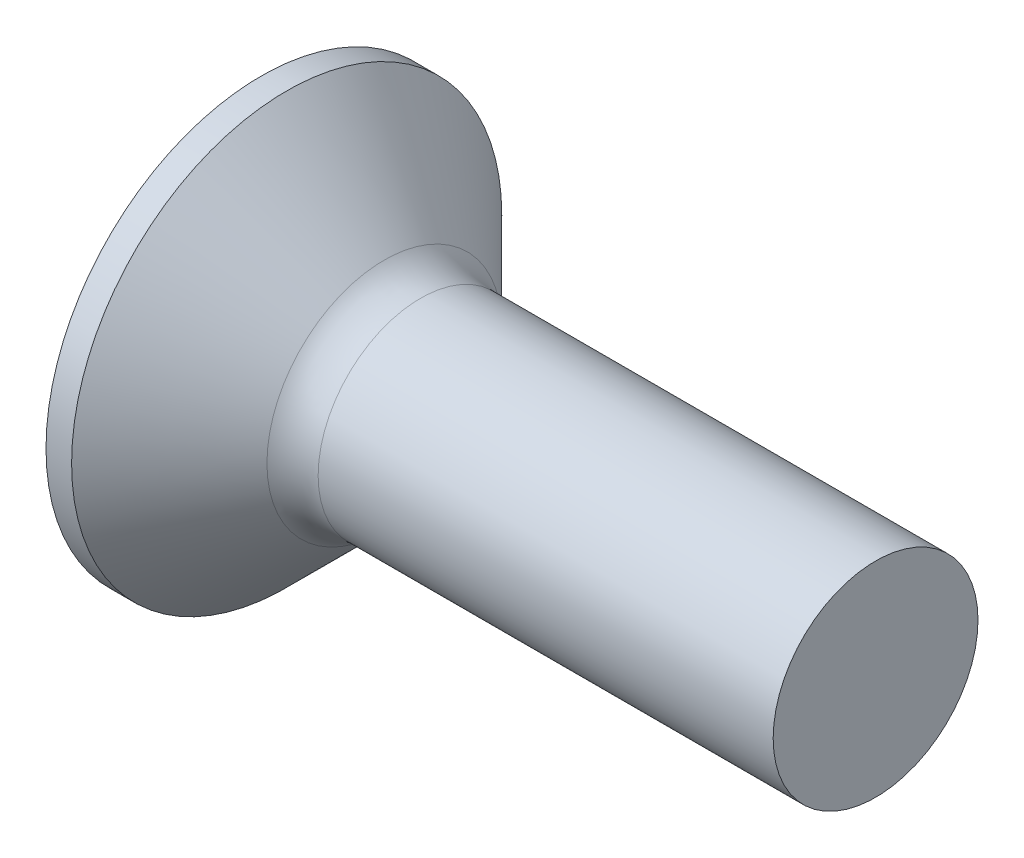
from build123d import *

# Parameters (mm, degrees)
FILLET1_R    = 1
SKETCH3_W    = 1.03
SKETCH3_H    = 4.4
SKETCH4_W    = 1.03
SKETCH4_H    = 1.897120414
RECPAT_COUNT = 2
RECPAT_ANGLE = 90


with BuildPart() as part:
    # BodySke → Base-Revolve (revolve)
    with BuildSketch(Plane.XY):
        Polygon((0, 0), (0, 4.2), (0.5, 4.2), (2.7, 2), (12, 2), (12, 0), align=None)
    revolve(axis=Axis((-6.35, 0, 0), (1, 0, 0)))

    # Fillet1
    fillet1_edges = [part.edges().sort_by_distance(p)[0] for p in [
        (2.7, -2, 0),
    ]]
    fillet(fillet1_edges, radius=FILLET1_R)

    # Sketch3 → Recess section 0
    with BuildSketch(Plane.ZY):
        Rectangle(SKETCH3_W, SKETCH3_H)
    # Sketch4 → Recess section 1
    with BuildSketch(Plane.ZY.offset(-2.51)):
        Rectangle(SKETCH4_W, SKETCH4_H)
    recess = loft(mode=Mode.SUBTRACT)

    # RecPat: Recess ×2 about axis
    recpat_axis = Axis((0, 0, 0), (1, 0, 0))
    for i in range(1, RECPAT_COUNT):
        add(recess.rotate(recpat_axis, i * RECPAT_ANGLE / (RECPAT_COUNT - 1)), mode=Mode.SUBTRACT)

    # RecCorSke → RecessCore (revolve, cut)
    with BuildSketch(Plane.XY):
        Polygon((0, 0), (0, 1.026516298), (2.51, 0.851), (2.786506661, 0), align=None)
    revolve(axis=Axis((-3.175, 0, 0), (1, 0, 0)), mode=Mode.SUBTRACT)


solid = part.part
